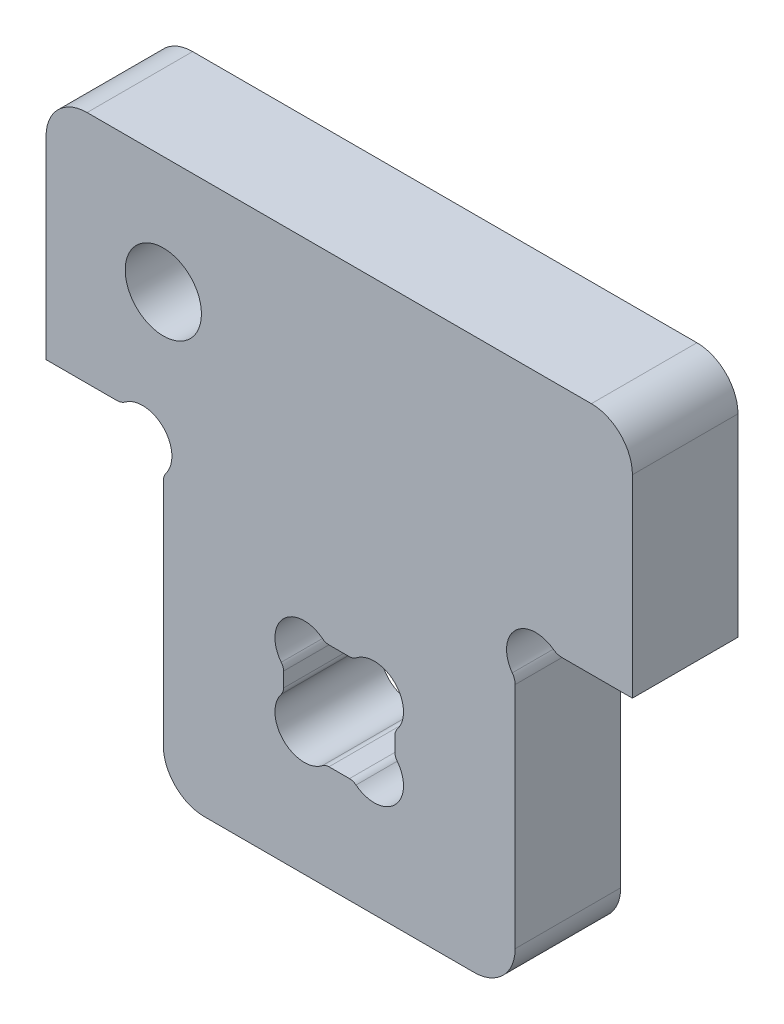
from build123d import *

# Parameters (mm, degrees)
BOSS_EXTRU_2_DEPTH      = 18
ENL_V_MAT_EXTRU_1_DEPTH = 19
CONG_1_R                = 7
ESQUISSE3_R             = 6.5
ENL_V_MAT_EXTRU_2_DEPTH = 19


with BuildPart() as part:
    # Esquisse2 → Boss.-Extru.2 (new body)
    with BuildSketch(Plane.XY):
        with BuildLine():
            Line((0, 0), (60, 0))
            Line((60, 0), (60, 46.012238509))
            ThreePointArc((60, 46.012238509), (59.874827529, 46.793387794), (59.511844635, 47.496314371))
            ThreePointArc((59.511844635, 47.496314371), (60, 54), (66.503685629, 54.488155365))
            ThreePointArc((66.503685629, 54.488155365), (67.206612206, 54.125172471), (67.987761491, 54))
            Line((67.987761491, 54), (80, 54))
            Line((80, 54), (80, 94))
            Line((80, 94), (-20, 94))
            Line((-20, 94), (-20, 54))
            Line((-20, 54), (-7.987761491, 54))
            ThreePointArc((-7.987761491, 54), (-7.206612206, 54.125172471), (-6.503685629, 54.488155365))
            ThreePointArc((-6.503685629, 54.488155365), (0, 54), (0.488155365, 47.496314371))
            ThreePointArc((0.488155365, 47.496314371), (0.125172471, 46.793387794), (0, 46.012238509))
            Line((0, 46.012238509), (0, 0))
        make_face()
    extrude(amount=BOSS_EXTRU_2_DEPTH)

    # Esquisse1 → Enlèv. mat.-Extru.1 (cut, through all)
    with BuildSketch(Plane.XY):
        with BuildLine():
            Line((39.5, 28.248771852), (39.5, 25.751228148))
            ThreePointArc((39.5, 25.751228148), (39.599672829, 25.160561143), (39.88765279, 24.635309084))
            ThreePointArc((39.88765279, 24.635309084), (39.5, 18), (32.864690916, 17.61234721))
            ThreePointArc((32.864690916, 17.61234721), (32.339438857, 17.900327171), (31.748771852, 18))
            Line((31.748771852, 18), (28.251228148, 18))
            ThreePointArc((28.251228148, 18), (27.660561143, 17.900327171), (27.135309084, 17.61234721))
            ThreePointArc((27.135309084, 17.61234721), (20.5, 18), (20.11234721, 24.635309084))
            ThreePointArc((20.11234721, 24.635309084), (20.400327171, 25.160561143), (20.5, 25.751228148))
            Line((20.5, 25.751228148), (20.5, 28.248771852))
            ThreePointArc((20.5, 28.248771852), (20.400327171, 28.839438857), (20.11234721, 29.364690916))
            ThreePointArc((20.11234721, 29.364690916), (20.5, 36), (27.135309084, 36.38765279))
            ThreePointArc((27.135309084, 36.38765279), (27.660561143, 36.099672829), (28.251228148, 36))
            Line((28.251228148, 36), (31.748771852, 36))
            ThreePointArc((31.748771852, 36), (32.339438857, 36.099672829), (32.864690916, 36.38765279))
            ThreePointArc((32.864690916, 36.38765279), (39.5, 36), (39.88765279, 29.364690916))
            ThreePointArc((39.88765279, 29.364690916), (39.599672829, 28.839438857), (39.5, 28.248771852))
        make_face()
    extrude(amount=ENL_V_MAT_EXTRU_1_DEPTH, mode=Mode.SUBTRACT)

    # Congé1
    cong_1_edges = [part.edges().sort_by_distance(p)[0] for p in [
        (-20, 94, 9),
        (80, 94, 9),
        (60, 0, 9),
        (0, 0, 9),
    ]]
    fillet(cong_1_edges, radius=CONG_1_R)

    # Esquisse3 → Enlèv. mat.-Extru.2 (cut, through all)
    with BuildSketch(Plane.XY.offset(18)):
        with Locations((0, 74)):
            Circle(ESQUISSE3_R)
    extrude(amount=-ENL_V_MAT_EXTRU_2_DEPTH, mode=Mode.SUBTRACT)


solid = part.part
